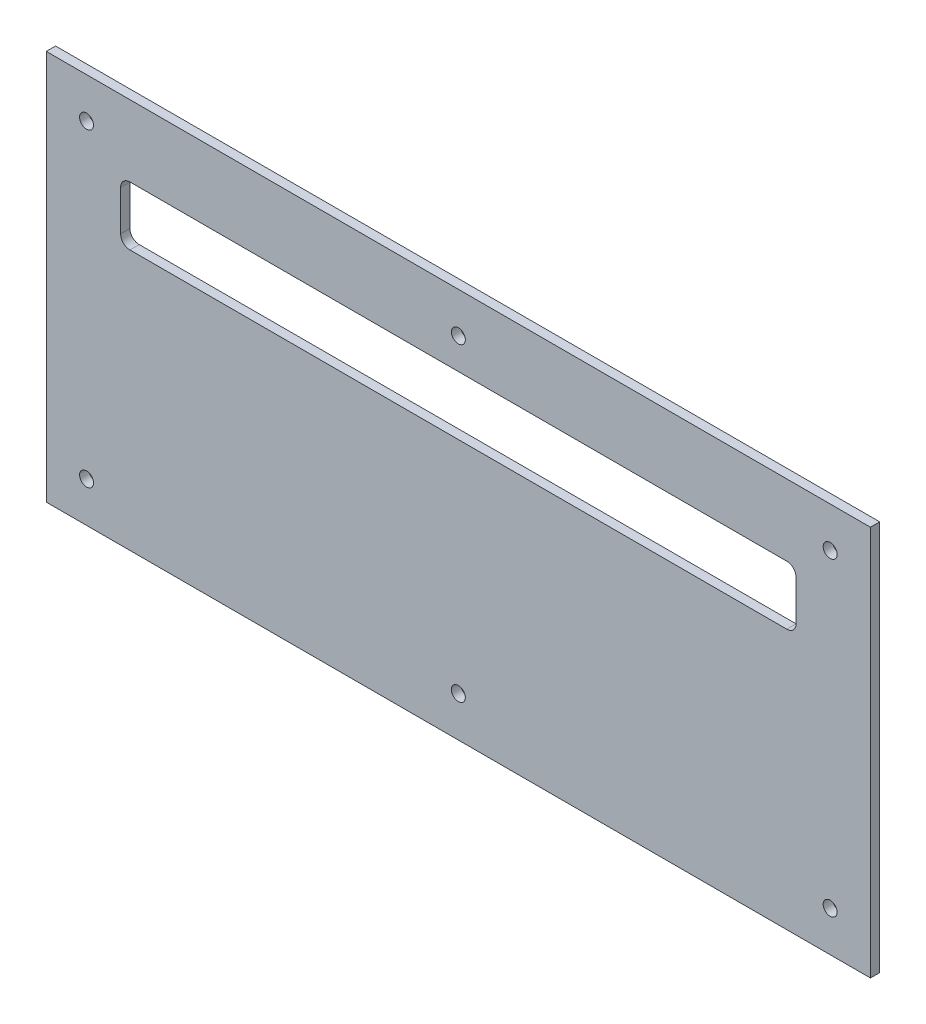
from build123d import *

# Parameters (mm, degrees)
SKETCH_1_W          = 266
SKETCH_1_H          = 126
EXTRUDE_1_DEPTH     = 3
SKETCH_2_W          = 220
SKETCH_2_H          = 19
CUT_EXTRUDE_1_DEPTH = 4
SKETCH_3_W          = 3
SKETCH_3_H          = 19
EXTRUDE_2_DEPTH     = 1
SKETCH_4_W          = 3
SKETCH_4_H          = 19
EXTRUDE_3_DEPTH     = 1
FILLET_1_R          = 3
SKETCH_5_R          = 2.25
CUT_EXTRUDE_2_DEPTH = 4


with BuildPart() as part:
    # Эскиз1 → Бобышка-Вытянуть1 (new body)
    with BuildSketch(Plane(origin=(0, 0, 0), x_dir=(-1, 0, 0), z_dir=(0, 0, -1))):
        with Locations((110, 60)):
            Rectangle(SKETCH_1_W, SKETCH_1_H)
    extrude(amount=EXTRUDE_1_DEPTH)

    # Эскиз2 → Вырез-Вытянуть1 (cut, through all)
    with BuildSketch(Plane.XY):
        with Locations((-110, 90.5)):
            Rectangle(SKETCH_2_W, SKETCH_2_H)
    extrude(amount=-CUT_EXTRUDE_1_DEPTH, mode=Mode.SUBTRACT)

    # Эскиз3 → Бобышка-Вытянуть2 (add)
    with BuildSketch(Plane.ZY):
        with Locations((-1.5, 90.5)):
            Rectangle(SKETCH_3_W, SKETCH_3_H)
    extrude(amount=EXTRUDE_2_DEPTH)

    # Эскиз4 → Бобышка-Вытянуть3 (add)
    with BuildSketch(Plane(origin=(-220, 0, 0), x_dir=(0, 0, -1), z_dir=(1, 0, 0))):
        with Locations((1.5, 90.5)):
            Rectangle(SKETCH_4_W, SKETCH_4_H)
    extrude(amount=EXTRUDE_3_DEPTH)

    # Скругление1
    fillet_1_edges = [part.edges().sort_by_distance(p)[0] for p in [
        (-1, 81, -1.5),
        (-1, 100, -1.5),
        (-219, 100, -1.5),
        (-219, 81, -1.5),
    ]]
    fillet(fillet_1_edges, radius=FILLET_1_R)

    # Эскиз5 → Вырез-Вытянуть2 (cut, through all)
    with BuildSketch(Plane(origin=(0, 0, -3), x_dir=(-1, 0, 0), z_dir=(0, 0, -1))):
        with Locations((230, 110)):
            Circle(SKETCH_5_R)
        with Locations((110, 110)):
            Circle(SKETCH_5_R)
        with Locations((-10, 110)):
            Circle(SKETCH_5_R)
        with Locations((-10, 10)):
            Circle(SKETCH_5_R)
        with Locations((110, 10)):
            Circle(SKETCH_5_R)
        with Locations((230, 10)):
            Circle(SKETCH_5_R)
    extrude(amount=-CUT_EXTRUDE_2_DEPTH, mode=Mode.SUBTRACT)


solid = part.part
